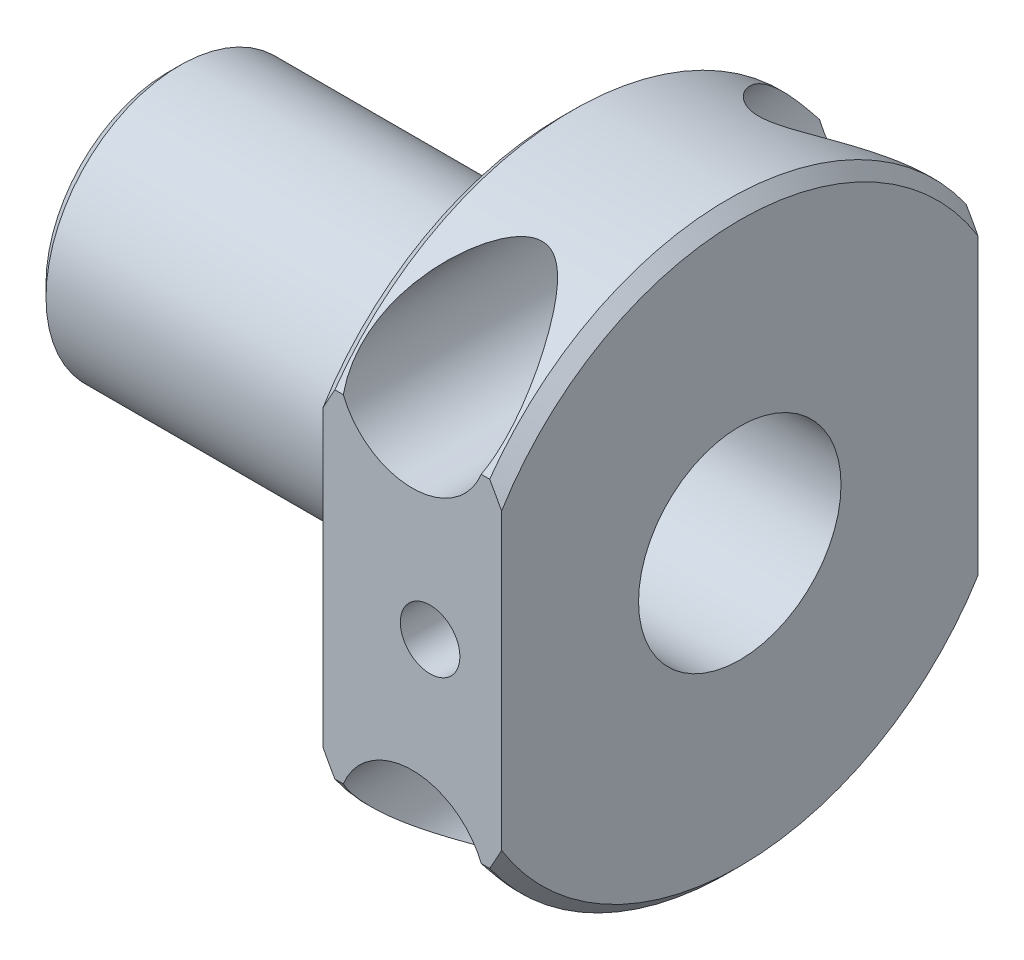
from build123d import *

# Parameters (mm, degrees)
SKETCH1_R               = 12.446
SKETCH1_R_2             = 4.318
BOSS_EXTRUDE1_DEPTH     = 22.86
SKETCH2_R               = 3.175
CUT_EXTRUDE1_DEPTH      = 13.446
SKETCH4_R               = 25.4
SKETCH4_R_2             = 5.715
CUT_EXTRUDE3_DEPTH      = 15.24
SKETCH7_R               = 1.27
CUT_EXTRUDE4_DEPTH      = 5.334
CUT_EXTRUDE4_DEPTH_BACK = 1.5080001
SKETCH8_R               = 5.715
SKETCH8_R_2             = 4.318
BOSS_EXTRUDE2_DEPTH     = 1.524
CHAMFER1_SIZE           = 0.508
SKETCH9_R               = 23.611709968
SKETCH9_W               = 20.32
SKETCH9_H               = 32.6206423
CUT_EXTRUDE5_DEPTH      = 13.97


with BuildPart() as part:
    # Sketch1 → Boss-Extrude1 (new body)
    with BuildSketch(Plane(origin=(0, 0, 0), x_dir=(0, 0, -1), z_dir=(1, 0, 0))):
        Circle(SKETCH1_R)
        Circle(SKETCH1_R_2, mode=Mode.SUBTRACT)
    extrude(amount=BOSS_EXTRUDE1_DEPTH)

    # Sketch2 → Cut-Extrude1 (cut, symmetric)
    with BuildSketch(Plane.XY):
        with Locations((19.05, 8.382)):
            Circle(SKETCH2_R)
    cut_extrude1 = extrude(amount=CUT_EXTRUDE1_DEPTH, both=True, mode=Mode.SUBTRACT)

    # Mirror1: Cut-Extrude1 across plane
    add(cut_extrude1.mirror(Plane.ZX), mode=Mode.SUBTRACT)

    # Sketch4 → Cut-Extrude3 (cut)
    with BuildSketch(Plane.ZY):
        Circle(SKETCH4_R)
        Circle(SKETCH4_R_2, mode=Mode.SUBTRACT)
    extrude(amount=-CUT_EXTRUDE3_DEPTH, mode=Mode.SUBTRACT)

    # Sketch7 → Cut-Extrude4 (cut, two sides)
    with BuildSketch(Plane(origin=(0, 0, 11.938), x_dir=(1, 0, 0), z_dir=(0, 0, -1))) as cut_extrude4_sk:
        with Locations((19.812, 0)):
            Circle(SKETCH7_R)
    extrude(amount=CUT_EXTRUDE4_DEPTH, mode=Mode.SUBTRACT)
    extrude(cut_extrude4_sk.sketch, amount=-CUT_EXTRUDE4_DEPTH_BACK, mode=Mode.SUBTRACT)

    # Sketch8 → Boss-Extrude2 (add)
    with BuildSketch(Plane.ZY):
        Circle(SKETCH8_R)
        Circle(SKETCH8_R_2, mode=Mode.SUBTRACT)
    extrude(amount=BOSS_EXTRUDE2_DEPTH)

    # Chamfer1
    chamfer1_edges = [part.edges().sort_by_distance(p)[0] for p in [
        (15.24, 0, 12.446),
        (-1.524, 0, -5.715),
        (22.86, 0, 12.446),
    ]]
    chamfer(chamfer1_edges, length=CHAMFER1_SIZE)

    # Sketch9 → Cut-Extrude5 (cut)
    with BuildSketch(Plane.ZY.offset(-15.24)):
        Circle(SKETCH9_R)
        Rectangle(SKETCH9_W, SKETCH9_H, mode=Mode.SUBTRACT)
    extrude(amount=-CUT_EXTRUDE5_DEPTH, mode=Mode.SUBTRACT)


solid = part.part
